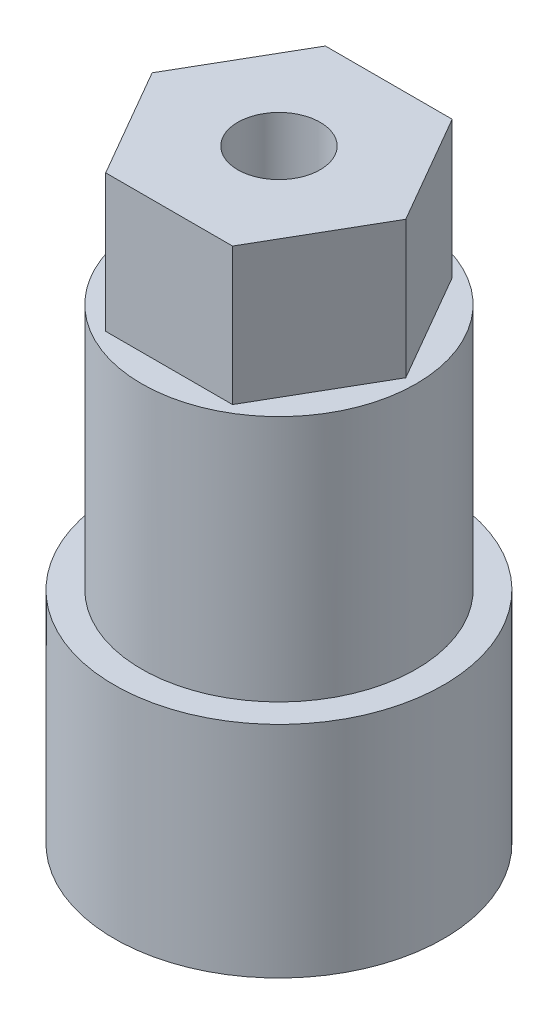
from build123d import *

# Parameters (mm, degrees)
SKETCH1_R           = 5
BOSS_EXTRUDE1_DEPTH = 9
SKETCH2_R           = 6
BOSS_EXTRUDE2_DEPTH = 8
BOSS_EXTRUDE3_DEPTH = 5
SKETCH4_R           = 1.5
CUT_EXTRUDE1_DEPTH  = 12


with BuildPart() as part:
    # Sketch1 → Boss-Extrude1 (new body)
    with BuildSketch(Plane(origin=(0, 0, 0), x_dir=(1, 0, 0), z_dir=(0, 1, 0))):
        Circle(SKETCH1_R)
    extrude(amount=BOSS_EXTRUDE1_DEPTH)

    # Sketch2 → Boss-Extrude2 (add)
    with BuildSketch(Plane.XZ):
        Circle(SKETCH2_R)
    extrude(amount=BOSS_EXTRUDE2_DEPTH)

    # Sketch3 → Boss-Extrude3 (add)
    with BuildSketch(Plane(origin=(0, 9, 0), x_dir=(1, 0, 0), z_dir=(0, 1, 0))):
        Polygon((4.618802154, 0), (2.309401077, 4), (-2.309401077, 4), (-4.618802154, 0), (-2.309401077, -4), (2.309401077, -4), align=None)
    extrude(amount=BOSS_EXTRUDE3_DEPTH)

    # Sketch4 → Cut-Extrude1 (cut)
    with BuildSketch(Plane(origin=(0, 14, 0), x_dir=(1, 0, 0), z_dir=(0, 1, 0))):
        Circle(SKETCH4_R)
    extrude(amount=-CUT_EXTRUDE1_DEPTH, mode=Mode.SUBTRACT)


solid = part.part
